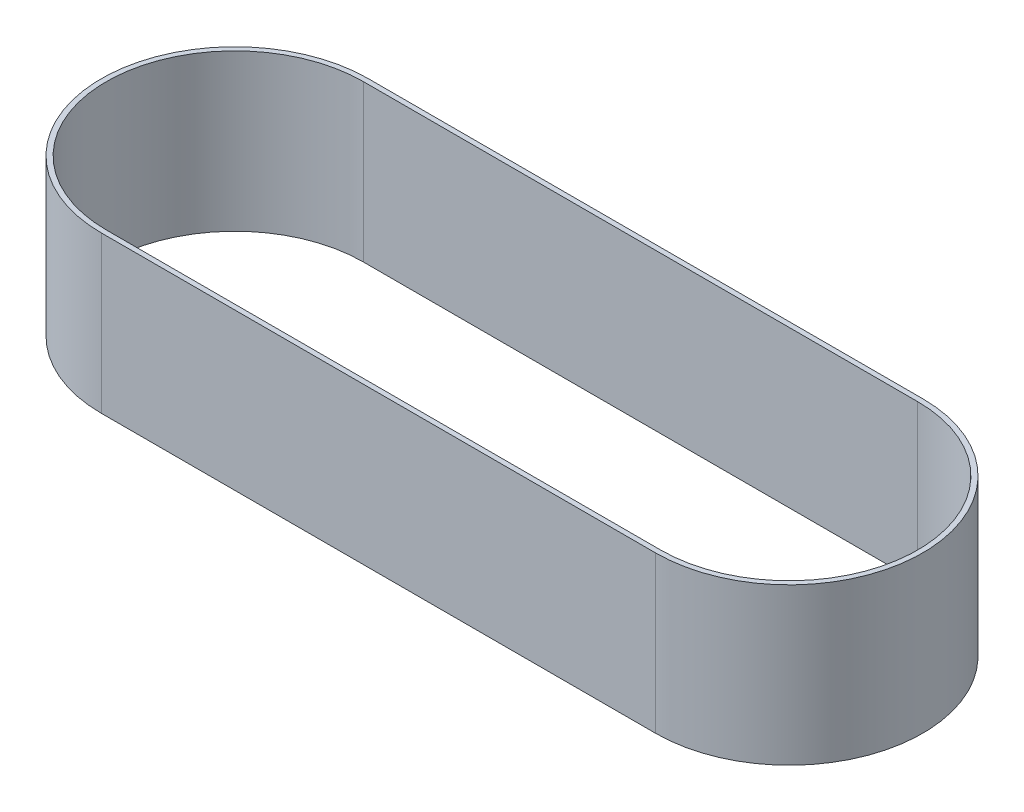
from build123d import *

# Parameters (mm, degrees)
BOSS_EXTRUDE1_DEPTH = 62


with BuildPart() as part:
    # Sketch1 → Boss-Extrude1 (new body)
    with BuildSketch(Plane(origin=(0, 0, 0), x_dir=(1, 0, 0), z_dir=(0, 1, 0))):
        with BuildLine():
            Line((-110, -53), (110, -53))
            ThreePointArc((110, -53), (163, 0), (110, 53))
            Line((110, 53), (-110, 53))
            ThreePointArc((-110, 53), (-163, 0), (-110, -53))
        make_face()
        with BuildLine():
            Line((-110, 51), (110, 51))
            ThreePointArc((110, 51), (161, 0), (110, -51))
            Line((110, -51), (-110, -51))
            ThreePointArc((-110, -51), (-161, 0), (-110, 51))
        make_face(mode=Mode.SUBTRACT)
    extrude(amount=BOSS_EXTRUDE1_DEPTH)


solid = part.part
